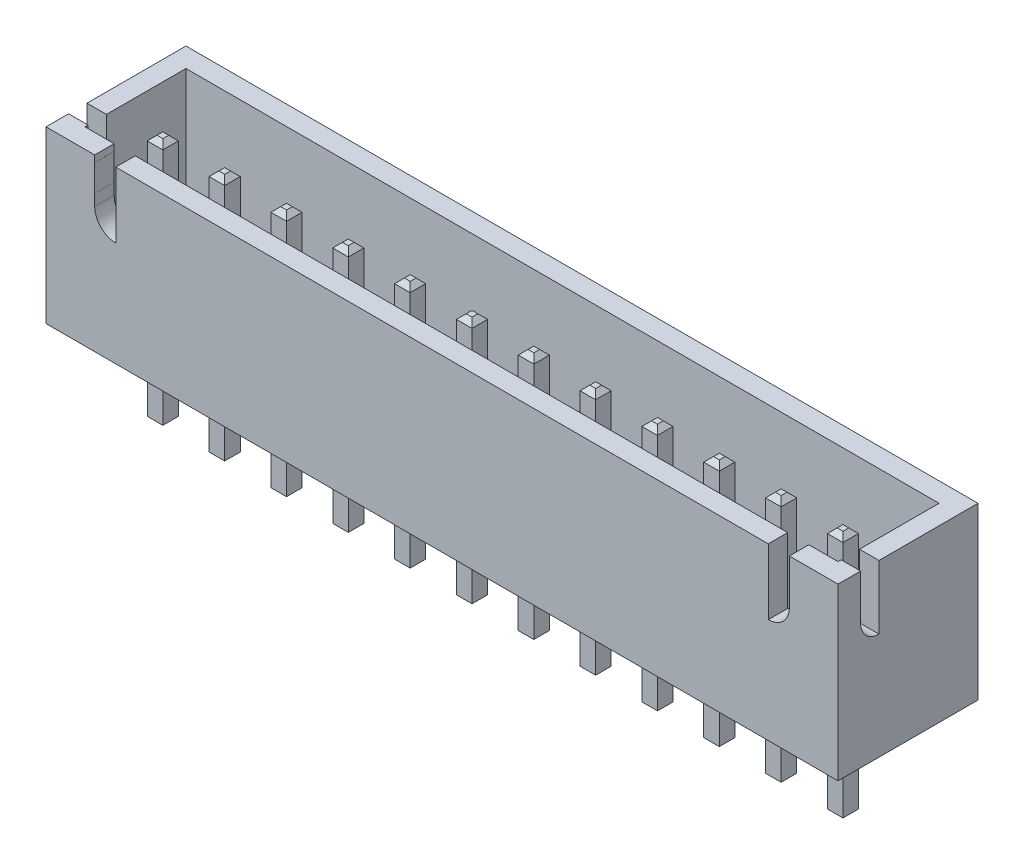
from build123d import *

# Parameters (mm, degrees)
SKETCH1_W                = 32.5374
SKETCH1_H                = 5.75
BOSS_EXTRUDE1_DEPTH      = 7
SHELL1_T                 = -0.8
CUT_EXTRUDE1_DEPTH       = 33.5374
CUT_EXTRUDE2_REACH       = 7.75
SKETCH4_W                = 0.64
SKETCH4_H                = 0.64
BOSS_EXTRUDE2_DEPTH      = 3.45
BOSS_EXTRUDE2_DEPTH_BACK = 6.75
CHAMFER1_SIZE            = 0.2


with BuildPart() as part:
    # Sketch1 → Boss-Extrude1 (new body)
    with BuildSketch(Plane(origin=(0, 0, 0), x_dir=(1, 0, 0), z_dir=(0, 1, 0))):
        Rectangle(SKETCH1_W, SKETCH1_H)
    extrude(amount=BOSS_EXTRUDE1_DEPTH)

    # Shell1
    shell1_openings = [part.faces().sort_by_distance(p)[0] for p in [
        (0, 7, 0),
    ]]
    offset(amount=SHELL1_T, openings=shell1_openings, kind=Kind.INTERSECTION)

    # Sketch2 → Cut-Extrude1 (cut, through all)
    with BuildSketch(Plane(origin=(16.2687, 0, 0), x_dir=(0, 0, -1), z_dir=(1, 0, 0))):
        with BuildLine():
            Line((-1.19301282, 7), (-1.19301282, 4.379603984))
            ThreePointArc((-1.19301282, 4.379603984), (-1.72610374, 4.600417472), (-1.946917229, 5.133508392))
            Line((-1.946917229, 5.133508392), (-1.946917229, 7))
            Line((-1.946917229, 7), (-1.19301282, 7))
        make_face()
    extrude(amount=-CUT_EXTRUDE1_DEPTH, mode=Mode.SUBTRACT)

    # Sketch3 → Cut-Extrude2 (cut, up to next)
    with BuildSketch(Plane.XY.offset(2.875), mode=Mode.PRIVATE) as cut_extrude2_sk1:
        with BuildLine():
            Line((-14.2687, 7), (-14.2687, 6.728922615))
            Line((-14.2687, 6.728922615), (-14.2687, 5.629880089))
            Line((-14.2687, 5.629880089), (-14.2687, 5.166308225))
            ThreePointArc((-14.2687, 5.166308225), (-14.014986554, 4.553789782), (-13.40246811, 4.300076336))
            Line((-13.40246811, 4.300076336), (-13.40246811, 7))
            Line((-13.40246811, 7), (-14.2687, 7))
        make_face()
    cut_extrude2_tool1 = extrude(cut_extrude2_sk1.sketch, amount=-CUT_EXTRUDE2_REACH, mode=Mode.PRIVATE) & part.part
    add(cut_extrude2_tool1.solids().sort_by_distance((-13.817865, 5.735551, 2.875))[0], mode=Mode.SUBTRACT)
    # Sketch3 → Cut-Extrude2 (cut, up to next)
    with BuildSketch(Plane.XY.offset(2.875), mode=Mode.PRIVATE) as cut_extrude2_sk2:
        with BuildLine():
            Line((13.40246811, 7), (14.2687, 7))
            Line((14.2687, 7), (14.268076048, 6.728922261))
            Line((14.268076048, 6.728922261), (14.2687, 5.629880089))
            Line((14.2687, 5.629880089), (14.2687, 5.166308225))
            ThreePointArc((14.2687, 5.166308225), (14.014986554, 4.553789782), (13.40246811, 4.300076336))
            Line((13.40246811, 4.300076336), (13.40246811, 7))
        make_face()
    cut_extrude2_tool2 = extrude(cut_extrude2_sk2.sketch, amount=-CUT_EXTRUDE2_REACH, mode=Mode.PRIVATE) & part.part
    add(cut_extrude2_tool2.solids().sort_by_distance((13.817777, 5.735411, 2.875))[0], mode=Mode.SUBTRACT)

    # Sketch4 → Boss-Extrude2 (add, two sides)
    with BuildSketch(Plane.XZ) as boss_extrude2_sk:
        with Locations((-13.8187, 0.525)):
            Rectangle(SKETCH4_W, SKETCH4_H)
        with Locations((-11.2787, 0.525)):
            Rectangle(SKETCH4_W, SKETCH4_H)
        with Locations((-8.7387, 0.525)):
            Rectangle(SKETCH4_W, SKETCH4_H)
        with Locations((-6.1987, 0.525)):
            Rectangle(SKETCH4_W, SKETCH4_H)
        with Locations((-3.6587, 0.525)):
            Rectangle(SKETCH4_W, SKETCH4_H)
        with Locations((-1.1187, 0.525)):
            Rectangle(SKETCH4_W, SKETCH4_H)
        with Locations((1.4213, 0.525)):
            Rectangle(SKETCH4_W, SKETCH4_H)
        with Locations((3.9613, 0.525)):
            Rectangle(SKETCH4_W, SKETCH4_H)
        with Locations((6.5013, 0.525)):
            Rectangle(SKETCH4_W, SKETCH4_H)
        with Locations((9.0413, 0.525)):
            Rectangle(SKETCH4_W, SKETCH4_H)
        with Locations((11.5813, 0.525)):
            Rectangle(SKETCH4_W, SKETCH4_H)
        with Locations((14.1213, 0.525)):
            Rectangle(SKETCH4_W, SKETCH4_H)
    extrude(amount=BOSS_EXTRUDE2_DEPTH)
    extrude(boss_extrude2_sk.sketch, amount=-BOSS_EXTRUDE2_DEPTH_BACK)

    # Chamfer1
    chamfer1_edges = [part.edges().sort_by_distance(p)[0] for p in [
        (-13.4987, 6.75, 0.525),
        (-13.8187, 6.75, 0.205),
        (-14.1387, 6.75, 0.525),
        (-13.8187, 6.75, 0.845),
        (-13.4987, -3.45, 0.525),
        (-13.8187, -3.45, 0.845),
        (-14.1387, -3.45, 0.525),
        (-13.8187, -3.45, 0.205),
        (-10.9587, 6.75, 0.525),
        (-11.2787, 6.75, 0.205),
        (-11.5987, 6.75, 0.525),
        (-11.2787, 6.75, 0.845),
        (-10.9587, -3.45, 0.525),
        (-11.2787, -3.45, 0.845),
        (-11.5987, -3.45, 0.525),
        (-11.2787, -3.45, 0.205),
        (-8.4187, 6.75, 0.525),
        (-8.7387, 6.75, 0.205),
        (-9.0587, 6.75, 0.525),
        (-8.7387, 6.75, 0.845),
        (-8.4187, -3.45, 0.525),
        (-8.7387, -3.45, 0.845),
        (-9.0587, -3.45, 0.525),
        (-8.7387, -3.45, 0.205),
        (-5.8787, 6.75, 0.525),
        (-6.1987, 6.75, 0.205),
        (-6.5187, 6.75, 0.525),
        (-6.1987, 6.75, 0.845),
        (-5.8787, -3.45, 0.525),
        (-6.1987, -3.45, 0.845),
        (-6.5187, -3.45, 0.525),
        (-6.1987, -3.45, 0.205),
        (-3.3387, 6.75, 0.525),
        (-3.6587, 6.75, 0.205),
        (-3.9787, 6.75, 0.525),
        (-3.6587, 6.75, 0.845),
        (-3.3387, -3.45, 0.525),
        (-3.6587, -3.45, 0.845),
        (-3.9787, -3.45, 0.525),
        (-3.6587, -3.45, 0.205),
        (-0.7987, 6.75, 0.525),
        (-1.1187, 6.75, 0.205),
        (-1.4387, 6.75, 0.525),
        (-1.1187, 6.75, 0.845),
        (-0.7987, -3.45, 0.525),
        (-1.1187, -3.45, 0.845),
        (-1.4387, -3.45, 0.525),
        (-1.1187, -3.45, 0.205),
        (1.7413, 6.75, 0.525),
        (1.4213, 6.75, 0.205),
        (1.1013, 6.75, 0.525),
        (1.4213, 6.75, 0.845),
        (1.7413, -3.45, 0.525),
        (1.4213, -3.45, 0.845),
        (1.1013, -3.45, 0.525),
        (1.4213, -3.45, 0.205),
        (4.2813, 6.75, 0.525),
        (3.9613, 6.75, 0.205),
        (3.6413, 6.75, 0.525),
        (3.9613, 6.75, 0.845),
        (4.2813, -3.45, 0.525),
        (3.9613, -3.45, 0.845),
        (3.6413, -3.45, 0.525),
        (3.9613, -3.45, 0.205),
        (6.8213, 6.75, 0.525),
        (6.5013, 6.75, 0.205),
        (6.1813, 6.75, 0.525),
        (6.5013, 6.75, 0.845),
        (6.8213, -3.45, 0.525),
        (6.5013, -3.45, 0.845),
        (6.1813, -3.45, 0.525),
        (6.5013, -3.45, 0.205),
        (9.3613, 6.75, 0.525),
        (9.0413, 6.75, 0.205),
        (8.7213, 6.75, 0.525),
        (9.0413, 6.75, 0.845),
        (9.3613, -3.45, 0.525),
        (9.0413, -3.45, 0.845),
        (8.7213, -3.45, 0.525),
        (9.0413, -3.45, 0.205),
        (11.9013, 6.75, 0.525),
        (11.5813, 6.75, 0.205),
        (11.2613, 6.75, 0.525),
        (11.5813, 6.75, 0.845),
        (11.9013, -3.45, 0.525),
        (11.5813, -3.45, 0.845),
        (11.2613, -3.45, 0.525),
        (11.5813, -3.45, 0.205),
        (14.4413, 6.75, 0.525),
        (14.1213, 6.75, 0.205),
        (13.8013, 6.75, 0.525),
        (14.1213, 6.75, 0.845),
        (14.4413, -3.45, 0.525),
        (14.1213, -3.45, 0.845),
        (13.8013, -3.45, 0.525),
        (14.1213, -3.45, 0.205),
    ]]
    chamfer(chamfer1_edges, length=CHAMFER1_SIZE)


solid = part.part
